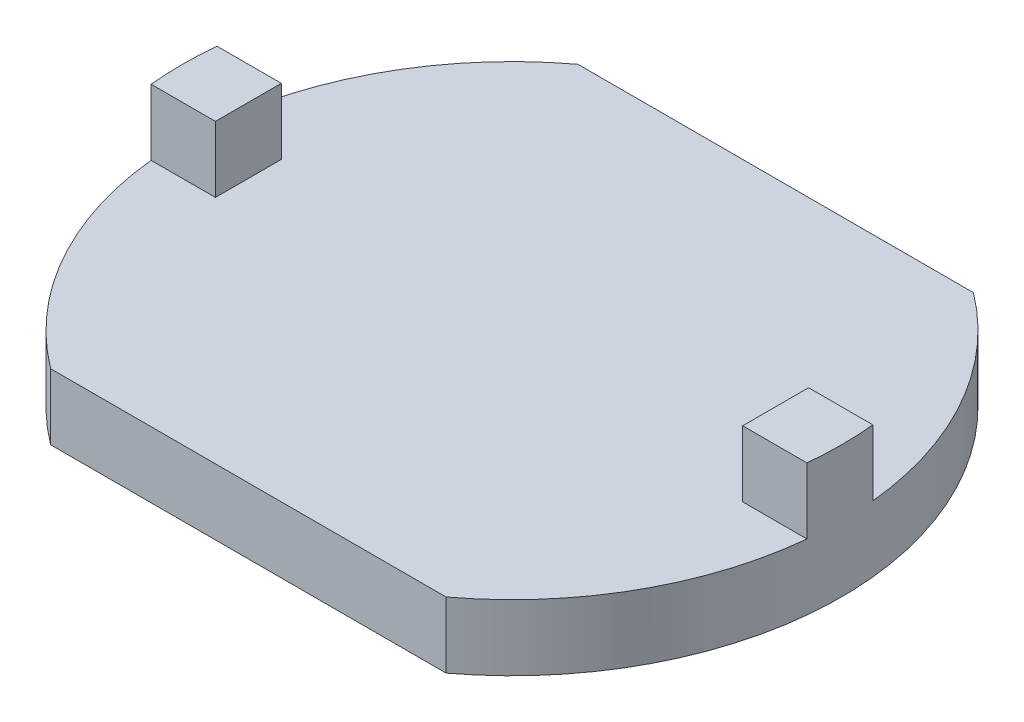
from build123d import *

# Parameters (mm, degrees)
BOSS_EXTRUDE1_DEPTH = 1
BOSS_EXTRUDE2_DEPTH = 1


with BuildPart() as part:
    # Sketch1 → Boss-Extrude1 (new body)
    with BuildSketch(Plane(origin=(0, 0, 0), x_dir=(1, 0, 0), z_dir=(0, 1, 0))):
        with BuildLine():
            Line((-3, 4), (3, 4))
            ThreePointArc((3, 4), (5, 0), (3, -4))
            Line((3, -4), (-3, -4))
            ThreePointArc((-3, -4), (-5, 0), (-3, 4))
        make_face()
    extrude(amount=BOSS_EXTRUDE1_DEPTH)

    # Sketch2 → Boss-Extrude2 (add)
    with BuildSketch(Plane(origin=(0, 1, 0), x_dir=(1, 0, 0), z_dir=(0, 1, 0))):
        with BuildLine():
            Line((4, 0.5), (4, -0.5))
            Line((4, -0.5), (4.974937186, -0.5))
            ThreePointArc((4.974937186, -0.5), (5, 0), (4.974937186, 0.5))
            Line((4.974937186, 0.5), (4, 0.5))
        make_face()
        with BuildLine():
            Line((-4, -0.5), (-4, 0.5))
            Line((-4, 0.5), (-4.974937186, 0.5))
            ThreePointArc((-4.974937186, 0.5), (-5, 0), (-4.974937186, -0.5))
            Line((-4.974937186, -0.5), (-4, -0.5))
        make_face()
    extrude(amount=BOSS_EXTRUDE2_DEPTH)


solid = part.part
